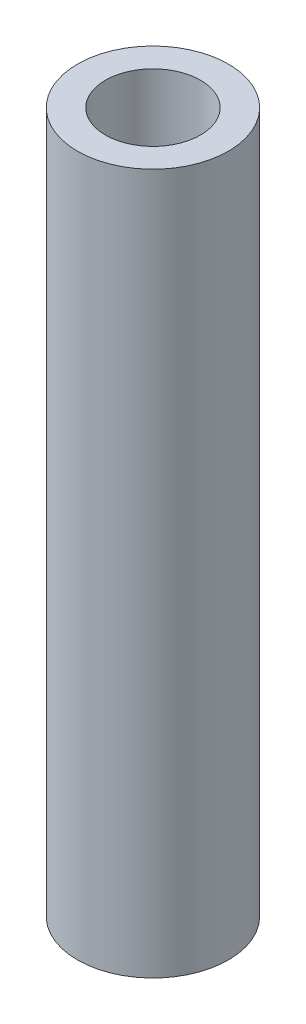
from build123d import *

# Parameters (mm, degrees)
SKETCH1_R           = 3.175
SKETCH1_R_2         = 2
BOSS_EXTRUDE1_DEPTH = 29.464


with BuildPart() as part:
    # Sketch1 → Boss-Extrude1 (new body)
    with BuildSketch(Plane(origin=(0, 0, 0), x_dir=(1, 0, 0), z_dir=(0, 1, 0))):
        Circle(SKETCH1_R)
        Circle(SKETCH1_R_2, mode=Mode.SUBTRACT)
    extrude(amount=-BOSS_EXTRUDE1_DEPTH)


solid = part.part
